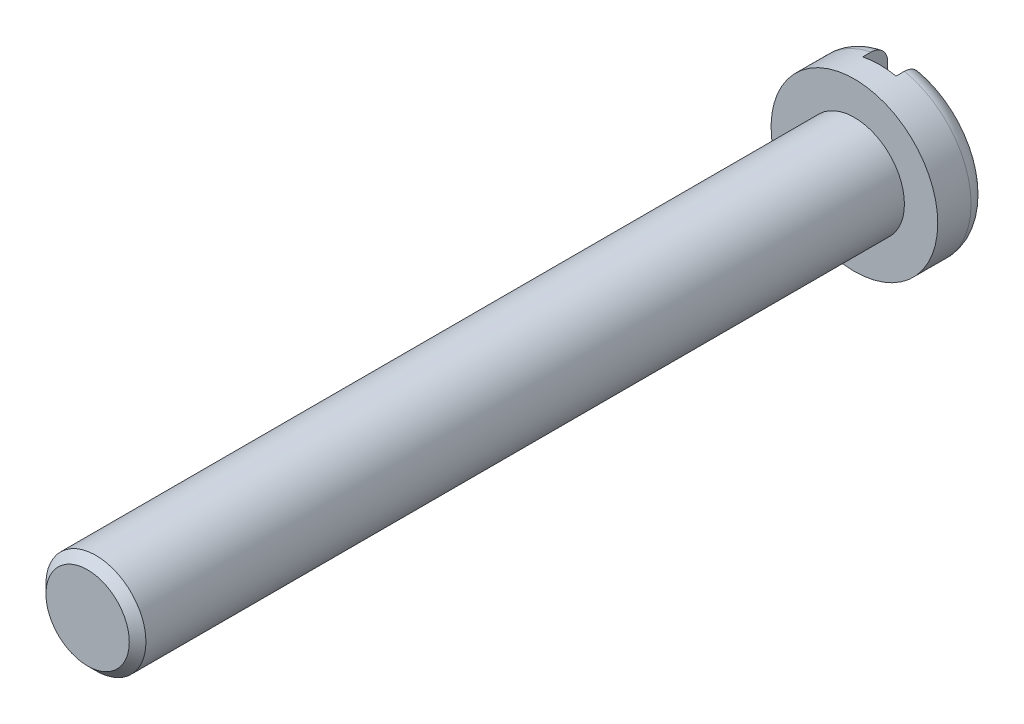
from build123d import *

# Parameters (mm, degrees)
ESQUISSE1_R             = 2.5
BASE_EXTRUSION_DEPTH    = 1.5
ESQUISSE2_R             = 1.5
BOSS_EXTRU_1_DEPTH      = 23
CHANFREIN1_SIZE         = 0.25
ESQUISSE3_W             = 1
ESQUISSE3_H             = 8
ENL_V_MAT_EXTRU_1_DEPTH = 0.75
CONG_1_R                = 0.5


with BuildPart() as part:
    # Esquisse1 → Base-Extrusion (new body)
    with BuildSketch(Plane.XY):
        Circle(ESQUISSE1_R)
    extrude(amount=BASE_EXTRUSION_DEPTH)

    # Esquisse2 → Boss.-Extru.1 (add)
    with BuildSketch(Plane.XY.offset(1.5)):
        Circle(ESQUISSE2_R)
    extrude(amount=BOSS_EXTRU_1_DEPTH)

    # Chanfrein1
    chanfrein1_edges = [part.edges().sort_by_distance(p)[0] for p in [
        (-1.5, 0, 24.5),
    ]]
    chamfer(chanfrein1_edges, length=CHANFREIN1_SIZE)

    # Esquisse3 → Enlèv. mat.-Extru.1 (cut)
    with BuildSketch(Plane(origin=(0, 0, 0), x_dir=(-1, 0, 0), z_dir=(0, 0, -1))):
        with Locations((0, -1)):
            Rectangle(ESQUISSE3_W, ESQUISSE3_H)
    extrude(amount=-ENL_V_MAT_EXTRU_1_DEPTH, mode=Mode.SUBTRACT)

    # Congé1
    cong_1_edges = [part.edges().sort_by_distance(p)[0] for p in [
        (1.936491673, 1.58113883, 0),
        (-2.5, 0, 0),
        (1.936491673, -1.58113883, 0),
    ]]
    fillet(cong_1_edges, radius=CONG_1_R)


solid = part.part
